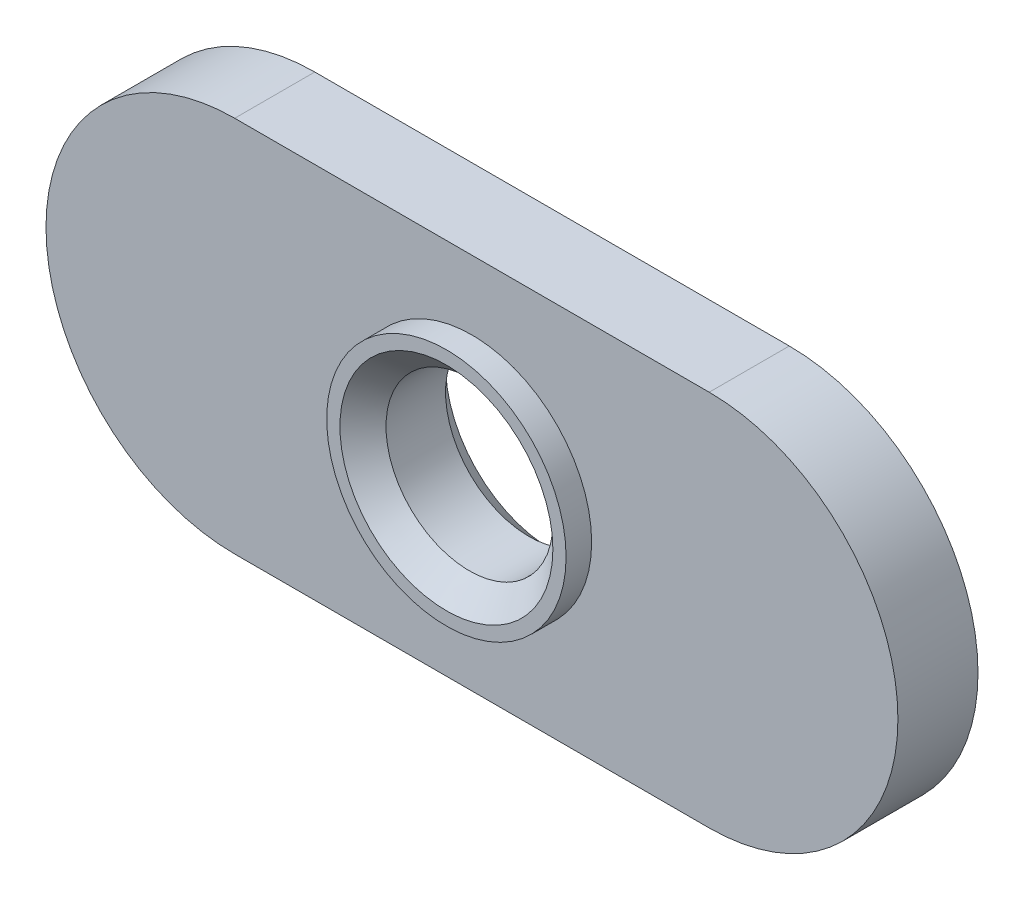
from build123d import *

# Parameters (mm, degrees)
BOSS_EXTRUDE1_DEPTH      = 1.1938
BOSS_EXTRUDE1_DEPTH_BACK = 1.1938
SKETCH2_R                = 3.5687
BOSS_EXTRUDE2_DEPTH      = 1.9558


with BuildPart() as part:
    # Sketch1 → Boss-Extrude1 (new, two sides: drawn at the far end of the back side and taken through both)
    with BuildSketch(Plane.XY.offset(-BOSS_EXTRUDE1_DEPTH_BACK)):
        with BuildLine():
            Line((-7.0739, -5.6261), (7.0739, -5.6261))
            ThreePointArc((7.0739, -5.6261), (12.7, 0), (7.0739, 5.6261))
            Line((7.0739, 5.6261), (-7.0739, 5.6261))
            ThreePointArc((-7.0739, 5.6261), (-12.7, 0), (-7.0739, -5.6261))
        make_face()
    extrude(amount=BOSS_EXTRUDE1_DEPTH + BOSS_EXTRUDE1_DEPTH_BACK)

    # Sketch2 → Boss-Extrude2 (add)
    with BuildSketch(Plane.XY):
        Circle(SKETCH2_R)
    extrude(amount=BOSS_EXTRUDE2_DEPTH)

    # Sketch3 → Cut-Revolve1 (revolve, cut)
    with BuildSketch(Plane(origin=(0, 0, 0), x_dir=(0, 0, -1), z_dir=(1, 0, 0))):
        Polygon((-1.9558, 0), (-1.9558, 3.175), (-1.26873, 2.48793), (0.50673, 2.48793), (1.1938, 3.175), (1.1938, 0), align=None)
    revolve(axis=Axis((0, 0, -1.1938), (0, 0, 1)), mode=Mode.SUBTRACT)


solid = part.part
